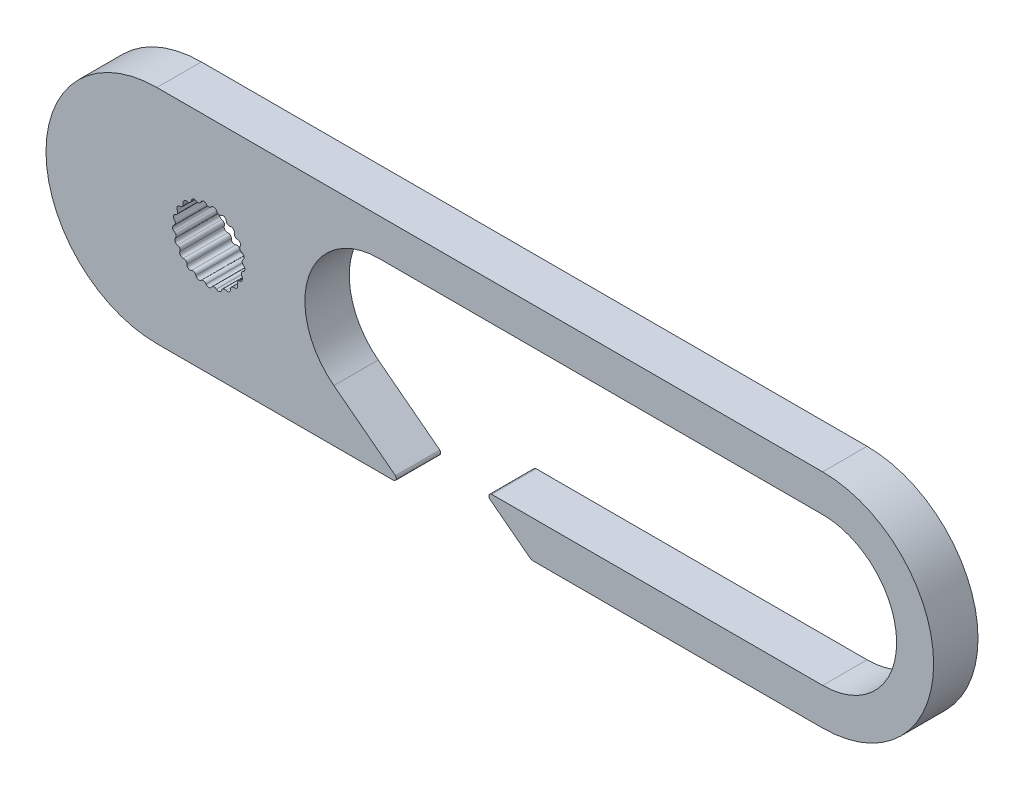
from build123d import *

# Parameters (mm, degrees)
BOSS_EXTRUDE1_DEPTH = 3


with BuildPart() as part:
    # Sketch2 → Boss-Extrude1 (new body)
    with BuildSketch(Plane.XY):
        with BuildLine():
            ThreePointArc((13.72796065, -3.112181063), (12.035436414, 2.462021021), (16.770370099, 5.855657737))
            Line((16.770370099, 5.855657737), (46.770370099, 5.855657737))
            ThreePointArc((46.770370099, 5.855657737), (51.770370099, 0.855657737), (46.770370099, -4.144342263))
            Line((46.770370099, -4.144342263), (24.407279181, -4.144342263))
            ThreePointArc((24.407279181, -4.144342263), (24.217881833, -4.280087732), (24.285582803, -4.503055815))
            Line((24.285582803, -4.503055815), (26.943586158, -6.541126143))
            ThreePointArc((26.943586158, -6.541126143), (27.087190775, -6.617835631), (27.247827103, -6.644342263))
            Line((27.247827103, -6.644342263), (46.770370099, -6.644342263))
            ThreePointArc((46.770370099, -6.644342263), (54.270370099, 0.855657737), (46.770370099, 8.355657737))
            Line((46.770370099, 8.355657737), (1.770370099, 8.355657737))
            ThreePointArc((1.770370099, 8.355657737), (-5.729629901, 0.855657737), (1.770370099, -6.644342263))
            Line((1.770370099, -6.644342263), (17.747827103, -6.644342263))
            ThreePointArc((17.747827103, -6.644342263), (17.93260301, -6.520878949), (17.889248459, -6.302920907))
            Line((17.889248459, -6.302920907), (13.72796065, -3.112181063))
        make_face()
        with BuildLine():
            ThreePointArc((5.103723485, 3.20079905), (5.270370099, 3.120917237), (5.437016713, 3.20079905))
            ThreePointArc((5.437016713, 3.20079905), (5.635523651, 3.278293261), (5.802369663, 3.145730953))
            ThreePointArc((5.802369663, 3.145730953), (5.938067058, 3.020278113), (6.120855608, 3.047491049))
            ThreePointArc((6.120855608, 3.047491049), (6.33338526, 3.063031463), (6.453745345, 2.887179801))
            ThreePointArc((6.453745345, 2.887179801), (6.546436212, 2.727302969), (6.729125133, 2.699429041))
            ThreePointArc((6.729125133, 2.699429041), (6.936793306, 2.651634823), (6.999972944, 2.448118998))
            ThreePointArc((6.999972944, 2.448118998), (7.041421292, 2.268023934), (7.207777872, 2.18753986))
            ThreePointArc((7.207777872, 2.18753986), (7.392132338, 2.080657737), (7.392517739, 1.867561025))
            ThreePointArc((7.392517739, 1.867561025), (7.379040701, 1.683249963), (7.514283428, 1.557307108))
            ThreePointArc((7.514283428, 1.557307108), (7.658943484, 1.400834025), (7.596500404, 1.197091003))
            ThreePointArc((7.596500404, 1.197091003), (7.529295473, 1.024940791), (7.621407438, 0.864729731))
            ThreePointArc((7.621407438, 0.864729731), (7.713519402, 0.672569008), (7.593796183, 0.496283137))
            ThreePointArc((7.593796183, 0.496283137), (7.478834813, 0.351590078), (7.519631462, 0.171346267))
            ThreePointArc((7.519631462, 0.171346267), (7.551010783, -0.039427773), (7.384645358, -0.172592718))
            ThreePointArc((7.384645358, -0.172592718), (7.232142372, -0.276972013), (7.217998744, -0.46123312))
            ThreePointArc((7.217998744, -0.46123312), (7.185857231, -0.671892277), (6.987631898, -0.750104008))
            ThreePointArc((6.987631898, -0.750104008), (6.811137854, -0.804894979), (6.743310674, -0.976800975))
            ThreePointArc((6.743310674, -0.976800975), (6.650504241, -1.16862726), (6.438032191, -1.18493632))
            ThreePointArc((6.438032191, -1.18493632), (6.253229361, -1.18527055), (6.137745369, -1.329546832))
            ThreePointArc((6.137745369, -1.329546832), (5.992520276, -1.485495637), (5.784680583, -1.438452896))
            ThreePointArc((5.784680583, -1.438452896), (5.607989508, -1.384300685), (5.455109966, -1.488127674))
            ThreePointArc((5.455109966, -1.488127674), (5.270370099, -1.594342263), (5.085630232, -1.488127674))
            ThreePointArc((5.085630232, -1.488127674), (4.93275069, -1.384300685), (4.756059614, -1.438452896))
            ThreePointArc((4.756059614, -1.438452896), (4.548219922, -1.485495637), (4.402994828, -1.329546832))
            ThreePointArc((4.402994828, -1.329546832), (4.287510837, -1.18527055), (4.102708006, -1.18493632))
            ThreePointArc((4.102708006, -1.18493632), (3.890235957, -1.16862726), (3.797429524, -0.976800975))
            ThreePointArc((3.797429524, -0.976800975), (3.729602343, -0.804894979), (3.5531083, -0.750104008))
            ThreePointArc((3.5531083, -0.750104008), (3.354882967, -0.671892277), (3.322741454, -0.46123312))
            ThreePointArc((3.322741454, -0.46123312), (3.308597826, -0.276972013), (3.15609484, -0.172592718))
            ThreePointArc((3.15609484, -0.172592718), (2.989729415, -0.039427773), (3.021108735, 0.171346267))
            ThreePointArc((3.021108735, 0.171346267), (3.061905384, 0.351590078), (2.946944015, 0.496283137))
            ThreePointArc((2.946944015, 0.496283137), (2.827220796, 0.672569008), (2.91933276, 0.864729731))
            ThreePointArc((2.91933276, 0.864729731), (3.011444724, 1.024940791), (2.944239794, 1.197091003))
            ThreePointArc((2.944239794, 1.197091003), (2.881796714, 1.400834025), (3.02645677, 1.557307108))
            ThreePointArc((3.02645677, 1.557307108), (3.161699497, 1.683249963), (3.148222459, 1.867561025))
            ThreePointArc((3.148222459, 1.867561025), (3.14860786, 2.080657737), (3.332962326, 2.18753986))
            ThreePointArc((3.332962326, 2.18753986), (3.499318906, 2.268023934), (3.540767254, 2.448118998))
            ThreePointArc((3.540767254, 2.448118998), (3.603946891, 2.651634823), (3.811615065, 2.699429041))
            ThreePointArc((3.811615065, 2.699429041), (3.994303986, 2.727302969), (4.086994852, 2.887179801))
            ThreePointArc((4.086994852, 2.887179801), (4.207354938, 3.063031463), (4.41988459, 3.047491049))
            ThreePointArc((4.41988459, 3.047491049), (4.60267314, 3.020278113), (4.738370535, 3.145730953))
            ThreePointArc((4.738370535, 3.145730953), (4.905216547, 3.278293261), (5.103723485, 3.20079905))
        make_face(mode=Mode.SUBTRACT)
    extrude(amount=BOSS_EXTRUDE1_DEPTH)


solid = part.part
